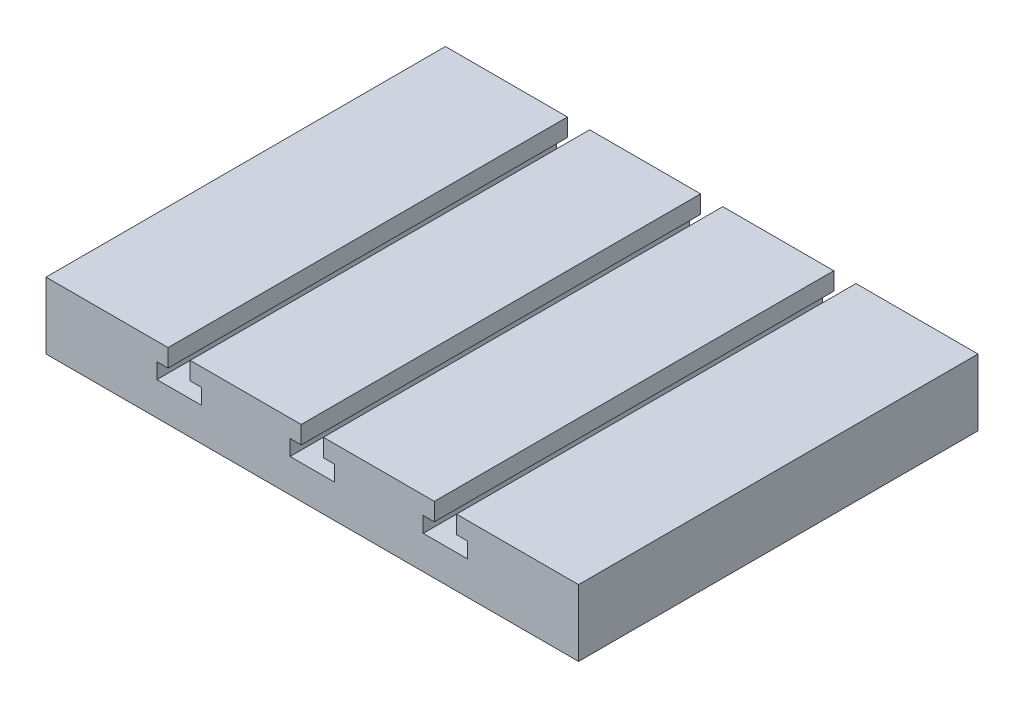
from build123d import *

# Parameters (mm, degrees)
SKETCH3_W           = 120
SKETCH3_H           = 15
BOSS_EXTRUDE2_DEPTH = 90
CUT_EXTRUDE1_DEPTH  = 90


with BuildPart() as part:
    # Sketch3 → Boss-Extrude2 (new body)
    with BuildSketch(Plane.XY):
        Rectangle(SKETCH3_W, SKETCH3_H)
    extrude(amount=BOSS_EXTRUDE2_DEPTH)

    # Sketch6 → Cut-Extrude1 (cut)
    with BuildSketch(Plane.XY.offset(90)):
        Polygon((32.5, 3.5), (35, 3.5), (35, 0), (25, 0), (25, 3.5), (27.5, 3.5), (27.5, 7.5), (32.5, 7.5), align=None)
        Polygon((-27.5, 3.5), (-25, 3.5), (-25, 0), (-35, 0), (-35, 3.5), (-32.5, 3.5), (-32.5, 7.5), (-27.5, 7.5), align=None)
        Polygon((-2.5, 7.5), (2.5, 7.5), (2.5, 3.5), (5, 3.5), (5, 0), (-5, 0), (-5, 3.5), (-2.5, 3.5), align=None)
    extrude(amount=-CUT_EXTRUDE1_DEPTH, mode=Mode.SUBTRACT)


solid = part.part
